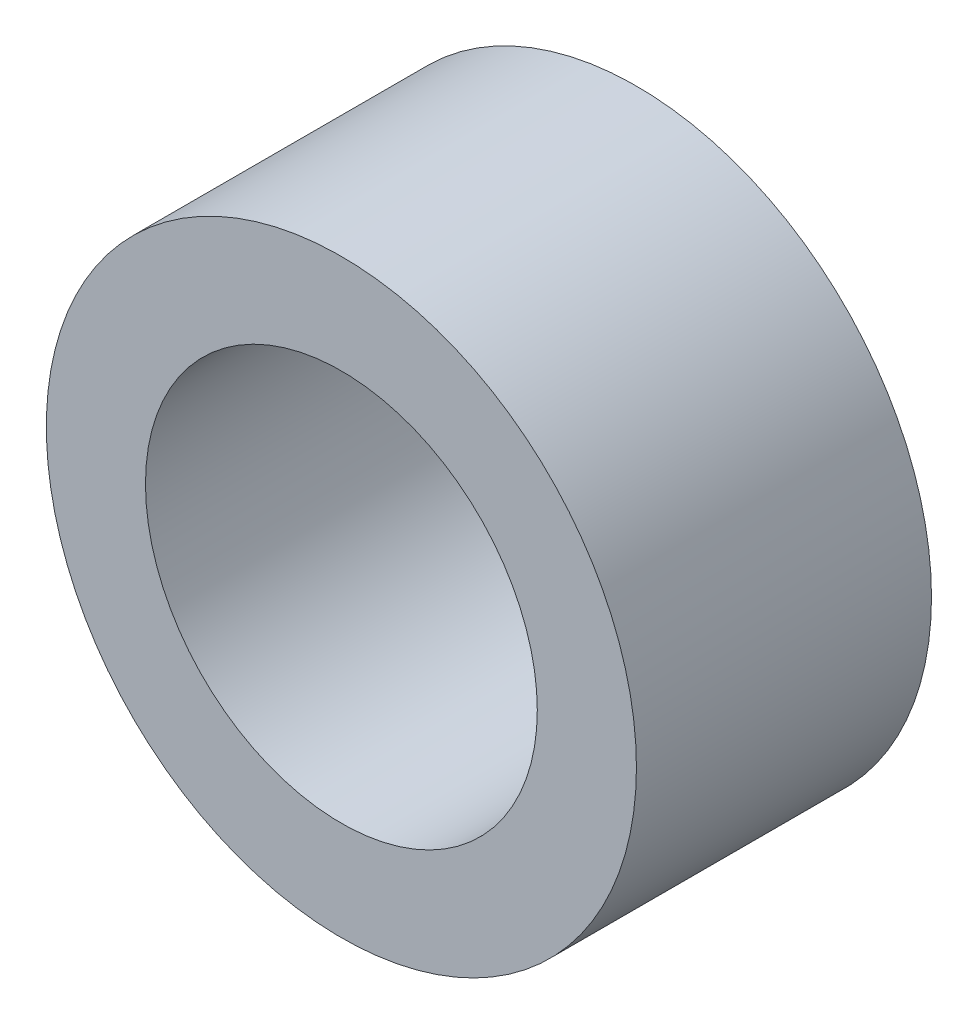
from build123d import *

# Parameters (mm, degrees)
SKETCH1_R      = 3.175
SKETCH1_R_2    = 2.1082
EXTRUDE1_DEPTH = 1.5875


with BuildPart() as part:
    # Sketch1 → Extrude1 (new body, symmetric)
    with BuildSketch(Plane.XY):
        Circle(SKETCH1_R)
        Circle(SKETCH1_R_2, mode=Mode.SUBTRACT)
    extrude(amount=EXTRUDE1_DEPTH, both=True)


solid = part.part
